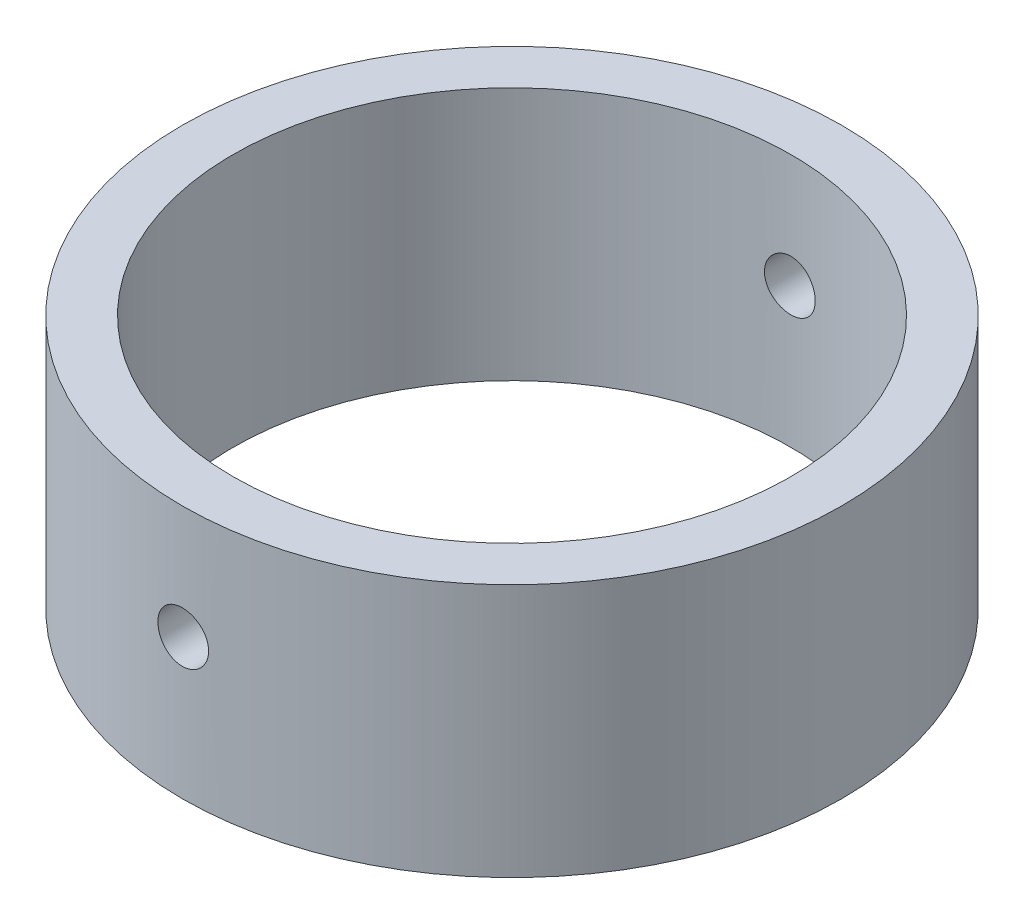
from build123d import *

# Parameters (mm, degrees)
SKETCH_1_R          = 13
SKETCH_1_R_2        = 11
EXTRUDE_1_DEPTH     = 10
SKETCH_2_R          = 1
CUT_EXTRUDE_1_DEPTH = 27


with BuildPart() as part:
    # 草图1 → 凸台-拉伸1 (new body)
    with BuildSketch(Plane(origin=(0, 0, 0), x_dir=(1, 0, 0), z_dir=(0, 1, 0))):
        Circle(SKETCH_1_R)
        Circle(SKETCH_1_R_2, mode=Mode.SUBTRACT)
    extrude(amount=EXTRUDE_1_DEPTH)

    # 草图2 → 切除-拉伸1 (cut, through all)
    with BuildSketch(Plane(origin=(0, 0, -13), x_dir=(-1, 0, 0), z_dir=(0, 0, -1))):
        with Locations((0, 5.523046221)):
            Circle(SKETCH_2_R)
    extrude(amount=-CUT_EXTRUDE_1_DEPTH, mode=Mode.SUBTRACT)


solid = part.part
